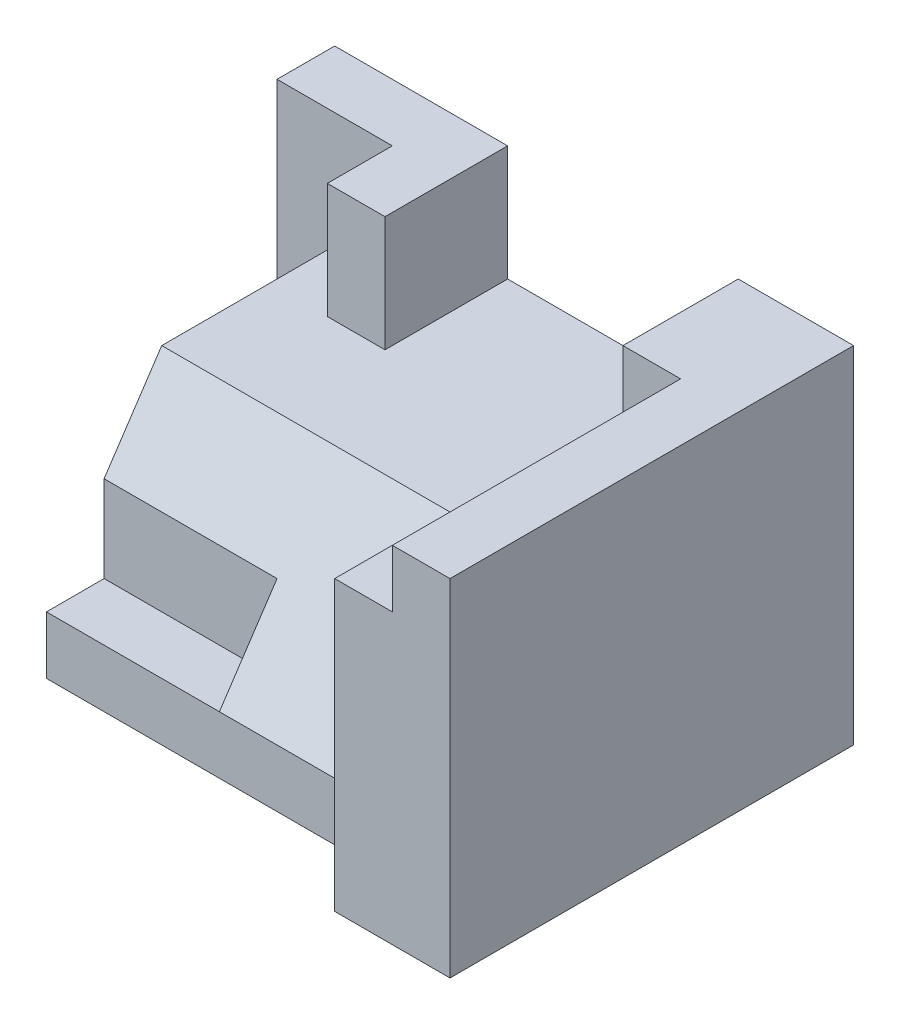
from build123d import *

# Parameters (mm, degrees)
SKETCH1_W           = 9
SKETCH1_H           = 7
BOSS_EXTRUDE1_DEPTH = 6
CUT_EXTRUDE1_DEPTH  = 7
SKETCH3_W           = 5
SKETCH3_H           = 4
CUT_EXTRUDE2_DEPTH  = 1
SKETCH4_W           = 1
SKETCH4_H           = 1
CUT_EXTRUDE3_DEPTH  = 5
SKETCH5_W           = 1
SKETCH5_H           = 1.5
CUT_EXTRUDE4_DEPTH  = 3
SKETCH6_W           = 4
SKETCH6_H           = 1
CUT_EXTRUDE5_DEPTH  = 2
SKETCH7_W           = 1
SKETCH7_H           = 1.127539311
BOSS_EXTRUDE2_DEPTH = 2


with BuildPart() as part:
    # Sketch1 → Boss-Extrude1 (new body)
    with BuildSketch(Plane(origin=(0, 0, 0), x_dir=(1, 0, 0), z_dir=(0, 1, 0))):
        with Locations((4.5, 3.5)):
            Rectangle(SKETCH1_W, SKETCH1_H)
    extrude(amount=BOSS_EXTRUDE1_DEPTH)

    # Sketch2 → Cut-Extrude1 (cut)
    with BuildSketch(Plane.ZY):
        Polygon((0, 0), (-1, 0), (-1, 1), (-3, 4), (-6, 4), (-6, 6), (0, 6), align=None)
    extrude(amount=-CUT_EXTRUDE1_DEPTH, mode=Mode.SUBTRACT)

    # Sketch3 → Cut-Extrude2 (cut)
    with BuildSketch(Plane.ZY):
        with Locations((-3.5, 2)):
            Rectangle(SKETCH3_W, SKETCH3_H)
    extrude(amount=-CUT_EXTRUDE2_DEPTH, mode=Mode.SUBTRACT)

    # Sketch4 → Cut-Extrude3 (cut)
    with BuildSketch(Plane.XY):
        with Locations((7.5, 5.5)):
            Rectangle(SKETCH4_W, SKETCH4_H)
    extrude(amount=-CUT_EXTRUDE3_DEPTH, mode=Mode.SUBTRACT)

    # Sketch5 → Cut-Extrude4 (cut)
    with BuildSketch(Plane.ZY.offset(-1)):
        with Locations((-1.5, 1.75)):
            Rectangle(SKETCH5_W, SKETCH5_H)
    extrude(amount=-CUT_EXTRUDE4_DEPTH, mode=Mode.SUBTRACT)

    # Sketch6 → Cut-Extrude5 (cut)
    with BuildSketch(Plane(origin=(0, 6, 0), x_dir=(1, 0, 0), z_dir=(0, 1, 0))):
        with Locations((5, 6.5)):
            Rectangle(SKETCH6_W, SKETCH6_H)
    extrude(amount=-CUT_EXTRUDE5_DEPTH, mode=Mode.SUBTRACT)

    # Sketch7 → Boss-Extrude2 (add)
    with BuildSketch(Plane(origin=(0, 4, 0), x_dir=(1, 0, 0), z_dir=(0, 1, 0))):
        with Locations((2.5, 5.436230345)):
            Rectangle(SKETCH7_W, SKETCH7_H)
    extrude(amount=BOSS_EXTRUDE2_DEPTH)


solid = part.part
